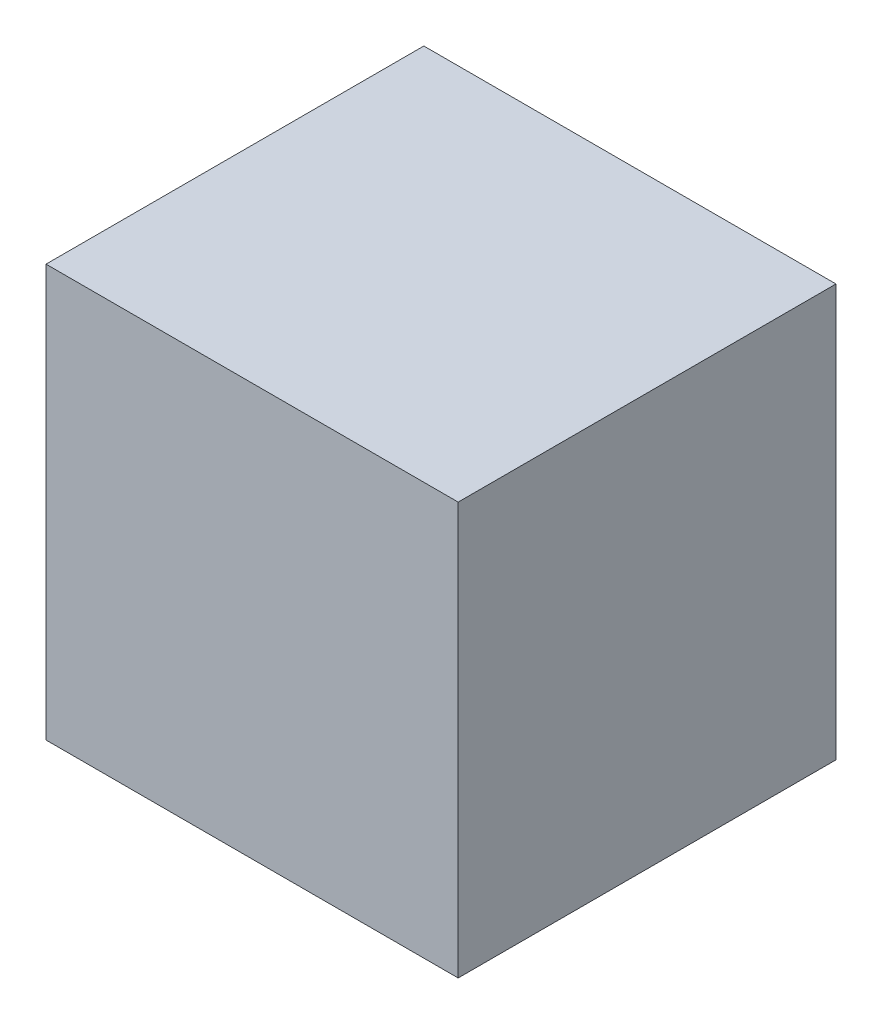
from build123d import *

# Parameters (mm, degrees)
SKETCH_1_W      = 1200
SKETCH_1_H      = 1200
EXTRUDE_1_DEPTH = 1100


with BuildPart() as part:
    # 草图1 → 凸台-拉伸1 (new body)
    with BuildSketch(Plane.XY):
        Rectangle(SKETCH_1_W, SKETCH_1_H)
    extrude(amount=EXTRUDE_1_DEPTH)


solid = part.part
